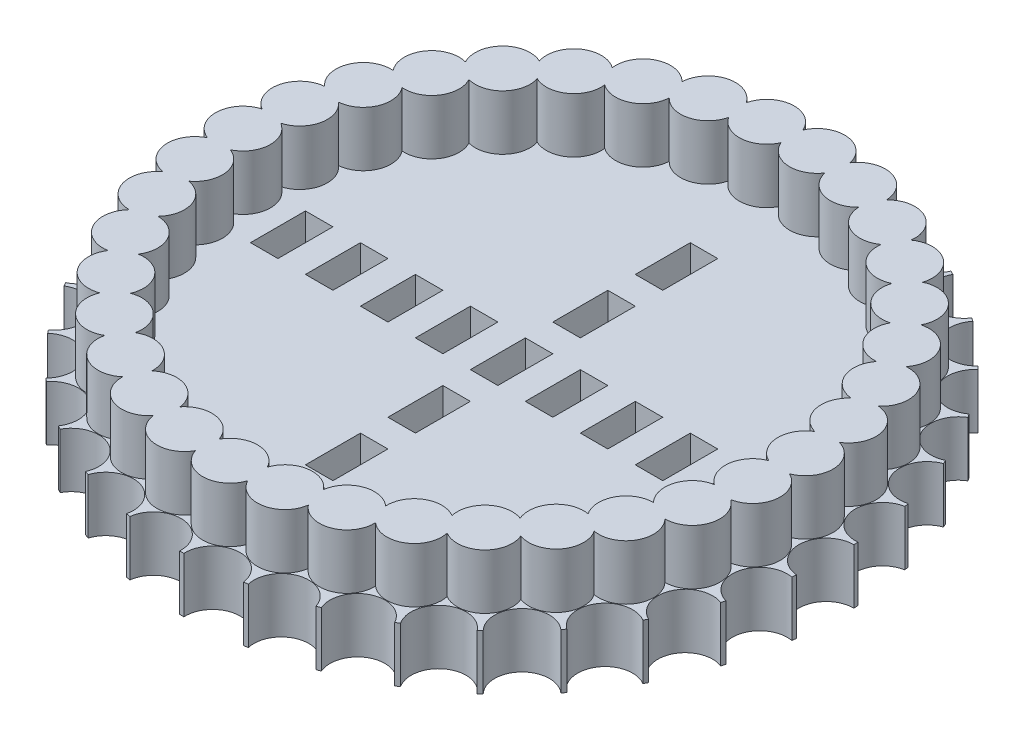
from build123d import *

# Parameters (mm, degrees)
SKETCH1_R           = 76.2
BOSS_EXTRUDE1_DEPTH = 12.7
SKETCH2_R           = 6.35
CUT_EXTRUDE1_DEPTH  = 13.7
CIRPATTERN1_COUNT   = 35
BOSS_EXTRUDE2_DEPTH = 12.7
SKETCH4_W           = 6.35
SKETCH4_H           = 12.7
CUT_EXTRUDE2_DEPTH  = 13.7


with BuildPart() as part:
    # Sketch1 → Boss-Extrude1 (new body)
    with BuildSketch(Plane(origin=(0, 0, 0), x_dir=(1, 0, 0), z_dir=(0, 1, 0))):
        Circle(SKETCH1_R)
    extrude(amount=BOSS_EXTRUDE1_DEPTH)

    # Sketch2 → Cut-Extrude1 (cut, through all)
    with BuildSketch(Plane(origin=(0, 12.7, 0), x_dir=(1, 0, 0), z_dir=(0, 1, 0))):
        with Locations((0, 76.2)):
            Circle(SKETCH2_R)
    cut_extrude1 = extrude(amount=-CUT_EXTRUDE1_DEPTH, mode=Mode.SUBTRACT)

    # CirPattern1: Cut-Extrude1 ×35 about axis
    cirpattern1_axis = Axis((0, 0, 0), (0, 1, 0))
    for i in range(1, CIRPATTERN1_COUNT):
        add(cut_extrude1.rotate(cirpattern1_axis, i * 360 / CIRPATTERN1_COUNT), mode=Mode.SUBTRACT)

    # Sketch3 → Boss-Extrude2 (add)
    with BuildSketch(Plane(origin=(0, 12.7, 0), x_dir=(1, 0, 0), z_dir=(0, 1, 0))):
        with BuildLine():
            ThreePointArc((12.014743691, 66.206694678), (6.398615122, 71.094436767), (0, 67.288041182))
            ThreePointArc((0, 67.288041182), (-6.398615122, 71.094436767), (-12.014743691, 66.206694678))
            ThreePointArc((-12.014743691, 66.206694678), (-18.990188611, 68.809403072), (-23.643323633, 62.997410532))
            ThreePointArc((-23.643323633, 62.997410532), (-30.971401813, 64.312778547), (-34.5119877, 57.763337777))
            ThreePointArc((-34.5119877, 57.763337777), (-41.957168677, 57.749088402), (-44.271408086, 50.672703818))
            ThreePointArc((-44.271408086, 50.672703818), (-51.594397618, 49.32929504), (-52.60790899, 41.953407464))
            ThreePointArc((-52.60790899, 41.953407464), (-59.573340167, 39.324017546), (-59.253548412, 31.885694075))
            ThreePointArc((-59.253548412, 31.885694075), (-65.637546546, 28.054833773), (-63.994730035, 20.793148243))
            ThreePointArc((-63.994730035, 20.793148243), (-69.592108173, 15.883944559), (-66.679068379, 9.032293518))
            ThreePointArc((-66.679068379, 9.032293518), (-71.309922182, 3.202532298), (-67.220286602, -3.018866552))
            ThreePointArc((-67.220286602, -3.018866552), (-70.735776618, -9.581811987), (-65.600989504, -14.972997768))
            ThreePointArc((-65.600989504, -14.972997768), (-67.888124992, -22.05818895), (-61.873222628, -26.445884516))
            ThreePointArc((-61.873222628, -26.445884516), (-62.85849317, -33.825597571), (-56.156799466, -37.068778775))
            ThreePointArc((-56.156799466, -37.068778775), (-55.808537658, -44.505823655), (-48.635450563, -46.500251984))
            ThreePointArc((-48.635450563, -46.500251984), (-46.964849826, -53.755595946), (-39.550918262, -54.437168835))
            ThreePointArc((-39.550918262, -54.437168835), (-36.611673077, -61.277619154), (-29.195186906, -60.624430287))
            ThreePointArc((-29.195186906, -60.624430287), (-25.081767032, -66.830129262), (-17.90109822, -64.863172669))
            ThreePointArc((-17.90109822, -64.863172669), (-12.745712357, -70.234664028), (-6.031653509, -67.017159311))
            ThreePointArc((-6.031653509, -67.017159311), (0, -71.381798903), (6.031653509, -67.017159311))
            ThreePointArc((6.031653509, -67.017159311), (12.745712357, -70.234664028), (17.90109822, -64.863172669))
            ThreePointArc((17.90109822, -64.863172669), (25.081767032, -66.830129262), (29.195186906, -60.624430287))
            ThreePointArc((29.195186906, -60.624430287), (36.611673077, -61.277619154), (39.550918263, -54.437168835))
            ThreePointArc((39.550918263, -54.437168835), (46.964849826, -53.755595946), (48.635450563, -46.500251984))
            ThreePointArc((48.635450563, -46.500251984), (55.808537658, -44.505823655), (56.156799466, -37.068778775))
            ThreePointArc((56.156799466, -37.068778775), (62.85849317, -33.825597571), (61.873222628, -26.445884516))
            ThreePointArc((61.873222628, -26.445884516), (67.888124992, -22.05818895), (65.600989504, -14.972997768))
            ThreePointArc((65.600989504, -14.972997768), (70.735776618, -9.581811987), (67.220286602, -3.018866552))
            ThreePointArc((67.220286602, -3.018866552), (71.309922182, 3.202532298), (66.679068379, 9.032293518))
            ThreePointArc((66.679068379, 9.032293518), (69.592108173, 15.883944559), (63.994730035, 20.793148243))
            ThreePointArc((63.994730035, 20.793148243), (65.637546546, 28.054833774), (59.253548412, 31.885694075))
            ThreePointArc((59.253548412, 31.885694075), (59.573340167, 39.324017546), (52.60790899, 41.953407464))
            ThreePointArc((52.60790899, 41.953407464), (51.594397618, 49.32929504), (44.271408086, 50.672703818))
            ThreePointArc((44.271408086, 50.672703818), (41.957168677, 57.749088402), (34.5119877, 57.763337777))
            ThreePointArc((34.5119877, 57.763337777), (30.971401813, 64.312778547), (23.643323633, 62.997410532))
            ThreePointArc((23.643323633, 62.997410532), (18.990188611, 68.809403072), (12.014743691, 66.206694678))
        make_face()
        with BuildLine():
            ThreePointArc((-54.818796784, 29.499252461), (-48.974259845, 32.327625882), (-48.670541249, 38.813461469))
            ThreePointArc((-48.670541249, 38.813461469), (-42.414902847, 40.552799397), (-40.957974472, 46.880173889))
            ThreePointArc((-40.957974472, 46.880173889), (-34.492295973, 47.474572573), (-31.928984695, 53.440118947))
            ThreePointArc((-31.928984695, 53.440118947), (-25.461078326, 52.870473924), (-21.873771078, 58.282454611))
            ThreePointArc((-21.873771078, 58.282454611), (-15.611520672, 56.567074742), (-11.115516462, 61.251544229))
            ThreePointArc((-11.115516462, 61.251544229), (-5.260195899, 58.445563233), (0, 62.251958818))
            ThreePointArc((0, 62.251958818), (5.260195899, 58.445563233), (11.115516462, 61.251544229))
            ThreePointArc((11.115516462, 61.251544229), (15.611520672, 56.567074742), (21.873771078, 58.282454611))
            ThreePointArc((21.873771078, 58.282454611), (25.461078326, 52.870473924), (31.928984695, 53.440118947))
            ThreePointArc((31.928984695, 53.440118947), (34.492295973, 47.474572573), (40.957974472, 46.880173889))
            ThreePointArc((40.957974472, 46.880173889), (42.414902847, 40.552799397), (48.670541249, 38.813461469))
            ThreePointArc((48.670541249, 38.813461469), (48.974259845, 32.327625882), (54.818796784, 29.499252461))
            ThreePointArc((54.818796784, 29.499252461), (53.959543835, 23.063415872), (59.205131086, 19.236913208))
            ThreePointArc((59.205131086, 19.236913208), (57.210523688, 13.057928698), (61.68856376, 8.356283736))
            ThreePointArc((61.68856376, 8.356283736), (58.622710237, 2.632748952), (62.189275238, -2.792923571))
            ThreePointArc((62.189275238, -2.792923571), (58.150714643, -7.877049511), (60.69117224, -13.852364017))
            ThreePointArc((60.69117224, -13.852364017), (55.809707235, -18.133673122), (57.242405029, -24.466578085))
            ThreePointArc((57.242405029, -24.466578085), (51.674929916, -27.807465558), (51.953819821, -34.294416202))
            ThreePointArc((51.953819821, -34.294416202), (45.879277831, -36.587503171), (44.995396097, -43.020003565))
            ThreePointArc((44.995396097, -43.020003565), (38.609028006, -44.191588328), (36.590783319, -50.362892617))
            ThreePointArc((36.590783319, -50.362892617), (30.097852254, -50.375319475), (27.010112659, -56.087076861))
            ThreePointArc((27.010112659, -56.087076861), (20.619306766, -54.939946405), (16.561314754, -60.008576306))
            ThreePointArc((16.561314754, -60.008576306), (10.478039793, -57.738758253), (5.580222566, -62.001350733))
            ThreePointArc((5.580222566, -62.001350733), (0, -58.681798903), (-5.580222566, -62.001350733))
            ThreePointArc((-5.580222566, -62.001350733), (-10.478039793, -57.738758253), (-16.561314754, -60.008576306))
            ThreePointArc((-16.561314754, -60.008576306), (-20.619306766, -54.939946405), (-27.010112659, -56.087076861))
            ThreePointArc((-27.010112659, -56.087076861), (-30.097852254, -50.375319475), (-36.590783319, -50.362892617))
            ThreePointArc((-36.590783319, -50.362892617), (-38.609028006, -44.191588328), (-44.995396097, -43.020003565))
            ThreePointArc((-44.995396097, -43.020003565), (-45.87927783, -36.587503171), (-51.953819821, -34.294416202))
            ThreePointArc((-51.953819821, -34.294416202), (-51.674929916, -27.807465558), (-57.242405029, -24.466578085))
            ThreePointArc((-57.242405029, -24.466578085), (-55.809707235, -18.133673122), (-60.69117224, -13.852364017))
            ThreePointArc((-60.69117224, -13.852364017), (-58.150714643, -7.877049511), (-62.189275238, -2.792923571))
            ThreePointArc((-62.189275238, -2.792923571), (-58.622710237, 2.632748952), (-61.68856376, 8.356283736))
            ThreePointArc((-61.68856376, 8.356283736), (-57.210523688, 13.057928698), (-59.205131086, 19.236913208))
            ThreePointArc((-59.205131086, 19.236913208), (-53.959543835, 23.063415871), (-54.818796784, 29.499252461))
        make_face(mode=Mode.SUBTRACT)
    extrude(amount=BOSS_EXTRUDE2_DEPTH)

    # Sketch4 → Cut-Extrude2 (cut, through all)
    with BuildSketch(Plane(origin=(0, 12.7, 0), x_dir=(1, 0, 0), z_dir=(0, 1, 0))):
        with Locations((12.7, 0)):
            Rectangle(SKETCH4_W, SKETCH4_H)
        Rectangle(SKETCH4_W, SKETCH4_H)
        with Locations((25.4, 0)):
            Rectangle(SKETCH4_W, SKETCH4_H)
        with Locations((38.1, 0)):
            Rectangle(SKETCH4_W, SKETCH4_H)
        with Locations((50.8, 0)):
            Rectangle(SKETCH4_W, SKETCH4_H)
        with Locations((0, 19.05)):
            Rectangle(SKETCH4_W, SKETCH4_H)
        with Locations((0, 38.1)):
            Rectangle(SKETCH4_W, SKETCH4_H)
        with Locations((0, -19.05)):
            Rectangle(SKETCH4_W, SKETCH4_H)
        with Locations((0, -38.1)):
            Rectangle(SKETCH4_W, SKETCH4_H)
        with Locations((-12.7, 0)):
            Rectangle(SKETCH4_W, SKETCH4_H)
        with Locations((-25.4, 0)):
            Rectangle(SKETCH4_W, SKETCH4_H)
        with Locations((-38.1, 0)):
            Rectangle(SKETCH4_W, SKETCH4_H)
        with Locations((-50.8, 0)):
            Rectangle(SKETCH4_W, SKETCH4_H)
    extrude(amount=-CUT_EXTRUDE2_DEPTH, mode=Mode.SUBTRACT)


solid = part.part
